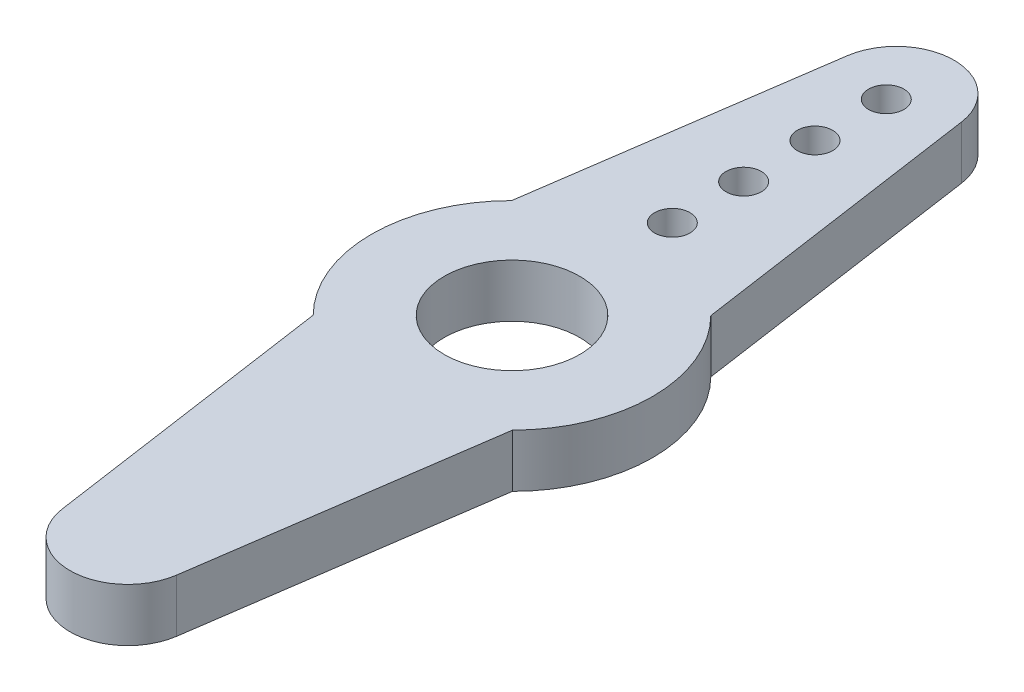
from build123d import *

# Parameters (mm, degrees)
SKETCH1_R           = 2.921
SKETCH1_R_2         = 0.762
BOSS_EXTRUDE1_DEPTH = 2.286


with BuildPart() as part:
    # Sketch1 → Boss-Extrude1 (new body)
    with BuildSketch(Plane(origin=(0, 0, 0), x_dir=(1, 0, 0), z_dir=(0, 1, 0))):
        with BuildLine():
            Line((-4.2926, 4.274545315), (-2.466531309, 16.914204067))
            ThreePointArc((-2.466531309, 16.914204067), (0, 19.05), (2.466531309, 16.914204067))
            Line((2.466531309, 16.914204067), (4.2926, 4.274545315))
            ThreePointArc((4.2926, 4.274545315), (6.0579, 0), (4.2926, -4.274545315))
            Line((4.2926, -4.274545315), (2.466531309, -16.914204067))
            ThreePointArc((2.466531309, -16.914204067), (0, -19.05), (-2.466531309, -16.914204067))
            Line((-2.466531309, -16.914204067), (-4.2926, -4.274545315))
            ThreePointArc((-4.2926, -4.274545315), (-6.0579, 0), (-4.2926, 4.274545315))
        make_face()
        Circle(SKETCH1_R, mode=Mode.SUBTRACT)
        with Locations((0, 16.129)):
            Circle(SKETCH1_R_2, mode=Mode.SUBTRACT)
        with Locations((0, 13.0556)):
            Circle(SKETCH1_R_2, mode=Mode.SUBTRACT)
        with Locations((0, 9.9822)):
            Circle(SKETCH1_R_2, mode=Mode.SUBTRACT)
        with Locations((0, 6.9088)):
            Circle(SKETCH1_R_2, mode=Mode.SUBTRACT)
    extrude(amount=BOSS_EXTRUDE1_DEPTH)


solid = part.part
